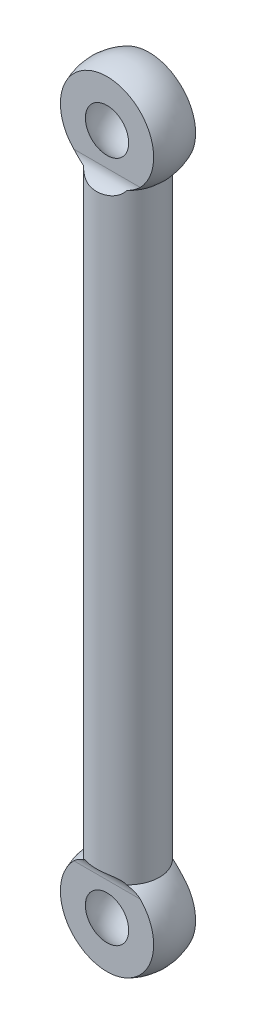
from build123d import *

# Parameters (mm, degrees)
SKETCH1_R               = 3.048
BOSS_EXTRUDE1_DEPTH     = 33.02
CUT_EXTRUDE1_DEPTH      = 5.953
CUT_EXTRUDE1_DEPTH_BACK = 5.953


with BuildPart() as part:
    # Sketch1 → Boss-Extrude1 (new body)
    with BuildSketch(Plane(origin=(0, 0, 0), x_dir=(1, 0, 0), z_dir=(0, 1, 0))):
        Circle(SKETCH1_R)
    extrude(amount=BOSS_EXTRUDE1_DEPTH)

    # Sketch2 → Revolve3 (revolve)
    with BuildSketch(Plane.XY):
        with BuildLine():
            Line((0, 37.973), (0, 35.941))
            ThreePointArc((0, 35.941), (-2.921, 33.02), (0, 30.099))
            Line((0, 30.099), (0, 28.067))
            ThreePointArc((0, 28.067), (-4.953, 33.02), (0, 37.973))
        make_face()
    revolve(axis=Axis((0, 37.973, 0), (0, -1, 0)))

    # Sketch3 → Cut-Extrude1 (cut, two sides)
    with BuildSketch(Plane(origin=(0, 0, 0), x_dir=(0, 0, -1), z_dir=(1, 0, 0))) as cut_extrude1_sk:
        with BuildLine():
            Line((-2.032, 37.973), (-2.032, 29.845))
            ThreePointArc((-2.032, 29.845), (-2.478369265, 28.767369265), (-3.556, 28.321))
            Line((-3.556, 28.321), (-6.35, 28.321))
            Line((-6.35, 28.321), (-6.35, 37.973))
            Line((-6.35, 37.973), (-2.032, 37.973))
        make_face()
        with BuildLine():
            Line((6.35, 37.973), (2.032, 37.973))
            Line((2.032, 37.973), (2.032, 29.845))
            ThreePointArc((2.032, 29.845), (2.478369265, 28.767369265), (3.556, 28.321))
            Line((3.556, 28.321), (6.35, 28.321))
            Line((6.35, 28.321), (6.35, 37.973))
        make_face()
    extrude(amount=CUT_EXTRUDE1_DEPTH, mode=Mode.SUBTRACT)
    extrude(cut_extrude1_sk.sketch, amount=-CUT_EXTRUDE1_DEPTH_BACK, mode=Mode.SUBTRACT)

    # Sketch4 → Cut-Revolve1 (revolve, cut)
    with BuildSketch(Plane.XY):
        with BuildLine():
            Line((0, 35.941), (0, 30.099))
            ThreePointArc((0, 30.099), (-2.921, 33.02), (0, 35.941))
        make_face()
    revolve(axis=Axis((0, 35.941, 0), (0, -1, 0)), mode=Mode.SUBTRACT)

    # Mirror1: part across plane


with BuildPart() as part_1:
    add(part.part)
    add(part.part.mirror(Plane.ZX))


solid = part_1.part
